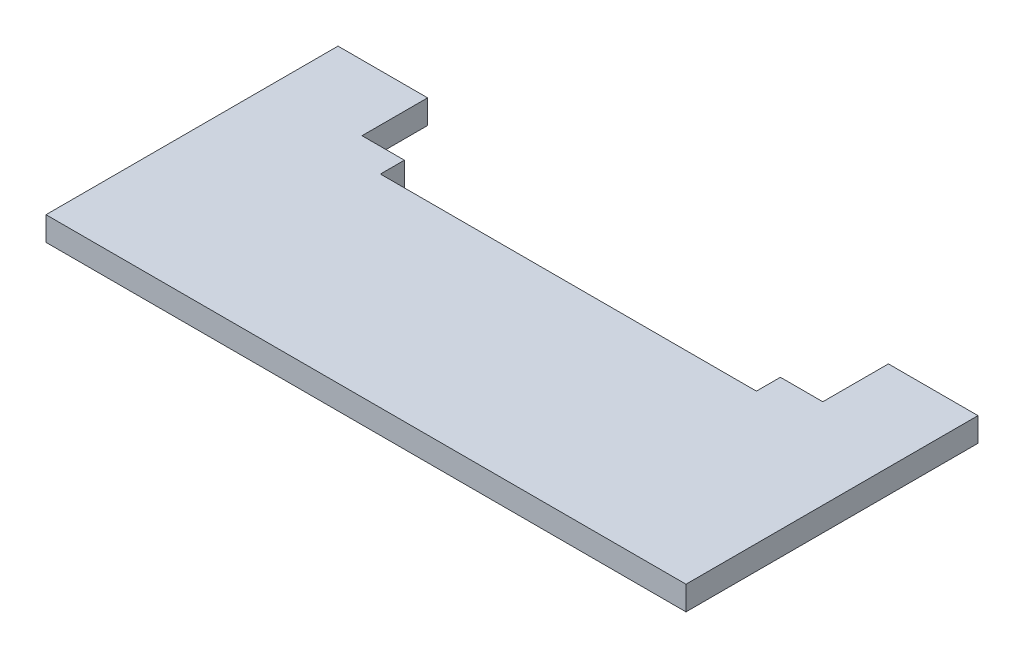
from build123d import *

# Parameters (mm, degrees)
BOSS_EXTRUDE1_DEPTH = 3


with BuildPart() as part:
    # Sketch1 → Boss-Extrude1 (new body)
    with BuildSketch(Plane(origin=(0, 0, 0), x_dir=(1, 0, 0), z_dir=(0, 1, 0))):
        Polygon((0, 0), (0, -36.5), (80, -36.5), (80, 0), (68.8, 0), (68.8, -8.2), (63.5, -8.2), (63.5, -11.2), (16.5, -11.2), (16.5, -8.2), (11.2, -8.2), (11.2, 0), align=None)
    extrude(amount=-BOSS_EXTRUDE1_DEPTH)


solid = part.part
